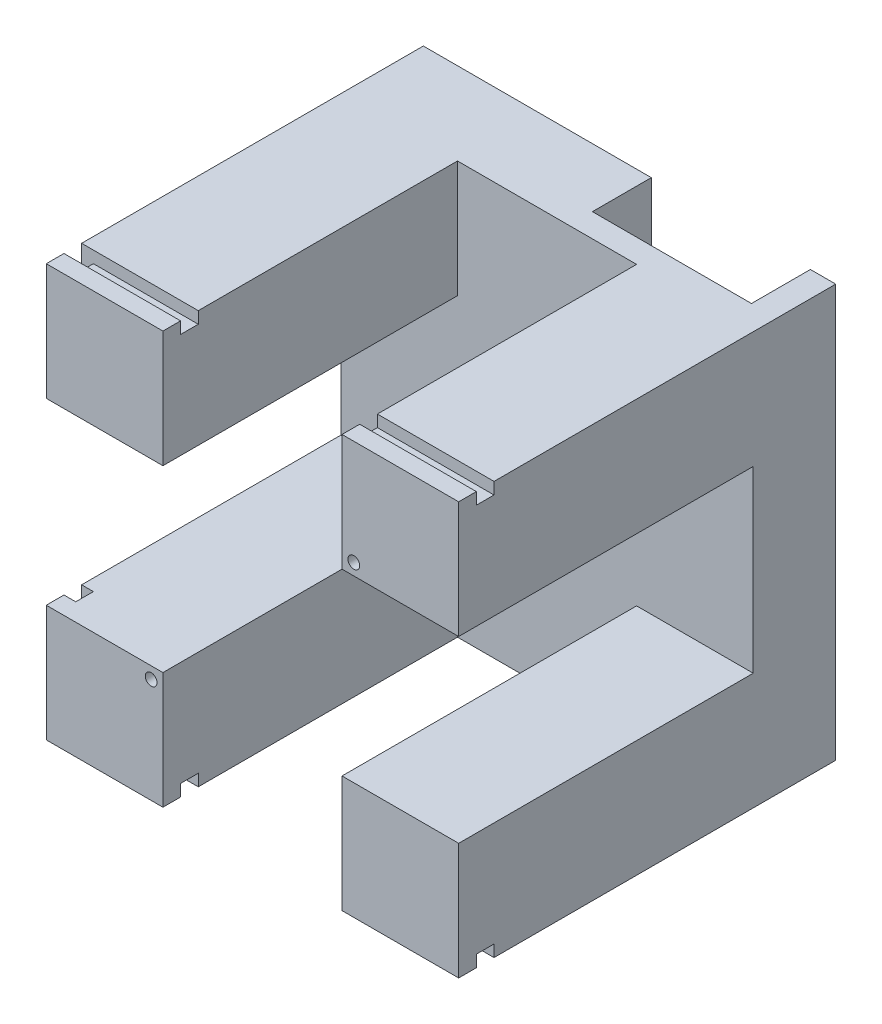
from build123d import *

# Parameters (mm, degrees)
ESQUISSE1_W                  = 70
ESQUISSE1_H                  = 70
BOSS_EXTRU_1_DEPTH           = 64
ESQUISSE2_W                  = 30.4
ESQUISSE2_H                  = 19.8
ESQUISSE2_H_2                = 30.4
ESQUISSE2_W_2                = 19.8
ENL_V_MAT_EXTRU_1_DEPTH      = 50
ESQUISSE5_W                  = 3
ESQUISSE5_H                  = 2
ENL_V_MAT_EXTRU_3_DEPTH      = 71
ESQUISSE6_W                  = 2
ESQUISSE6_H                  = 3
ENL_V_MAT_EXTRU_4_DEPTH      = 71
ESQUISSE7_R                  = 1
ENL_V_MAT_EXTRU_5_DEPTH      = 65
ENL_V_MAT_EXTRU_7_DEPTH      = 10
BOSS_EXTRU_2_DEPTH           = 3.8
ESQUISSE10_W                 = 27
ESQUISSE10_H                 = 18.1
ENL_V_MAT_EXTRU_8_DEPTH      = 10
ESQUISSE11_R                 = 1.25
ENL_V_MAT_EXTRU_9_DEPTH      = 15
R_P_TITION_CIRCULAIRE1_COUNT = 2


with BuildPart() as part:
    # Esquisse1 → Boss.-Extru.1 (new body)
    with BuildSketch(Plane.XY):
        with Locations((-35, 35)):
            Rectangle(ESQUISSE1_W, ESQUISSE1_H)
    extrude(amount=BOSS_EXTRU_1_DEPTH)

    # Esquisse2 → Enlèv. mat.-Extru.1 (cut)
    with BuildSketch(Plane.XY.offset(64)):
        with Locations((-35, 60.1)):
            Rectangle(ESQUISSE2_W, ESQUISSE2_H)
        with Locations((-35, 35)):
            Rectangle(ESQUISSE2_W, ESQUISSE2_H_2)
        with Locations((-9.9, 35)):
            Rectangle(ESQUISSE2_W_2, ESQUISSE2_H_2)
        with Locations((-60.1, 35)):
            Rectangle(ESQUISSE2_W_2, ESQUISSE2_H_2)
        with Locations((-35, 9.9)):
            Rectangle(ESQUISSE2_W, ESQUISSE2_H)
    extrude(amount=-ENL_V_MAT_EXTRU_1_DEPTH, mode=Mode.SUBTRACT)

    # Esquisse5 → Enlèv. mat.-Extru.3 (cut, through all)
    with BuildSketch(Plane.ZY.offset(70)):
        with Locations((59.5, 69)):
            Rectangle(ESQUISSE5_W, ESQUISSE5_H)
        with Locations((59.5, 1)):
            Rectangle(ESQUISSE5_W, ESQUISSE5_H)
    extrude(amount=-ENL_V_MAT_EXTRU_3_DEPTH, mode=Mode.SUBTRACT)

    # Esquisse6 → Enlèv. mat.-Extru.4 (cut, through all)
    with BuildSketch(Plane(origin=(0, 70, 0), x_dir=(1, 0, 0), z_dir=(0, 1, 0))):
        with Locations((-69, -59.5)):
            Rectangle(ESQUISSE6_W, ESQUISSE6_H)
    extrude(amount=-ENL_V_MAT_EXTRU_4_DEPTH, mode=Mode.SUBTRACT)

    # Esquisse7 → Enlèv. mat.-Extru.5 (cut, through all)
    with BuildSketch(Plane.XY.offset(64)):
        with Locations((-52.2, 17.8)):
            Circle(ESQUISSE7_R)
    enl_v_mat_extru_5 = extrude(amount=-ENL_V_MAT_EXTRU_5_DEPTH, mode=Mode.SUBTRACT)

    # Esquisse8 → Enlèv. mat.-Extru.7 (cut)
    with BuildSketch(Plane(origin=(0, 0, 0), x_dir=(-1, 0, 0), z_dir=(0, 0, -1))):
        with BuildLine():
            Line((60.2, 0), (60.2, 17.8))
            ThreePointArc((60.2, 17.8), (52.2, 9.8), (44.2, 17.8))
            Line((44.2, 17.8), (44.2, 0))
            Line((44.2, 0), (60.2, 0))
        make_face()
        with BuildLine():
            ThreePointArc((44.2, 17.8), (52.2, 9.8), (60.2, 17.8))
            Line((60.2, 17.8), (53.2, 17.8))
            ThreePointArc((53.2, 17.8), (52.2, 16.8), (51.2, 17.8))
            Line((51.2, 17.8), (44.2, 17.8))
        make_face()
        with BuildLine():
            Line((53.2, 17.8), (60.2, 17.8))
            ThreePointArc((60.2, 17.8), (52.2, 25.8), (44.2, 17.8))
            Line((44.2, 17.8), (51.2, 17.8))
            ThreePointArc((51.2, 17.8), (52.2, 18.8), (53.2, 17.8))
        make_face()
    enl_v_mat_extru_7 = extrude(amount=-ENL_V_MAT_EXTRU_7_DEPTH, mode=Mode.SUBTRACT)

    # Esquisse9 → Boss.-Extru.2 (add)
    with BuildSketch(Plane(origin=(0, 0, 0), x_dir=(-1, 0, 0), z_dir=(0, 0, -1))):
        with BuildLine():
            Line((46.2, 0), (46.2, 17.8))
            ThreePointArc((46.2, 17.8), (52.2, 23.8), (58.2, 17.8))
            Line((58.2, 17.8), (58.2, 0))
            Line((58.2, 0), (60.2, 0))
            Line((60.2, 0), (60.2, 17.8))
            Line((60.2, 17.8), (60.175717696, 28.742363645))
            Line((60.175717696, 28.742363645), (44.2, 28.742363645))
            Line((44.2, 28.742363645), (44.2, 0))
            Line((44.2, 0), (46.2, 0))
        make_face()
    extrude(amount=-BOSS_EXTRU_2_DEPTH)

    # Esquisse10 → Enlèv. mat.-Extru.8 (cut)
    with BuildSketch(Plane(origin=(0, 0, 0), x_dir=(-1, 0, 0), z_dir=(0, 0, -1))):
        with Locations((52.2, 9.05)):
            Rectangle(ESQUISSE10_W, ESQUISSE10_H)
    enl_v_mat_extru_8 = extrude(amount=-ENL_V_MAT_EXTRU_8_DEPTH, mode=Mode.SUBTRACT)

    # Esquisse11 → Enlèv. mat.-Extru.9 (cut)
    with BuildSketch(Plane.XZ.offset(-18.1)):
        with Locations(Location((-41.7, 7, 0), (0, 0, 270))):  # turned: the seam where the file's is
            Circle(ESQUISSE11_R)
        with Locations(Location((-62.7, 7, 0), (0, 0, 270))):  # turned: the seam where the file's is
            Circle(ESQUISSE11_R)
    extrude(amount=-ENL_V_MAT_EXTRU_9_DEPTH, mode=Mode.SUBTRACT)

    # Répétition circulaire1: Enlèv. mat.-Extru.5, Enlèv. mat.-Extru.7, Enlèv. mat.-Extru.8 ×2 about axis
    r_p_tition_circulaire1_axis = Axis((-35, 35, 0), (0, 0, 1))
    add([enl_v_mat_extru_5.rotate(r_p_tition_circulaire1_axis, i * 360 / R_P_TITION_CIRCULAIRE1_COUNT) for i in range(1, R_P_TITION_CIRCULAIRE1_COUNT)], mode=Mode.SUBTRACT)
    add([enl_v_mat_extru_7.rotate(r_p_tition_circulaire1_axis, i * 360 / R_P_TITION_CIRCULAIRE1_COUNT) for i in range(1, R_P_TITION_CIRCULAIRE1_COUNT)], mode=Mode.SUBTRACT)
    add([enl_v_mat_extru_8.rotate(r_p_tition_circulaire1_axis, i * 360 / R_P_TITION_CIRCULAIRE1_COUNT) for i in range(1, R_P_TITION_CIRCULAIRE1_COUNT)], mode=Mode.SUBTRACT)


solid = part.part
